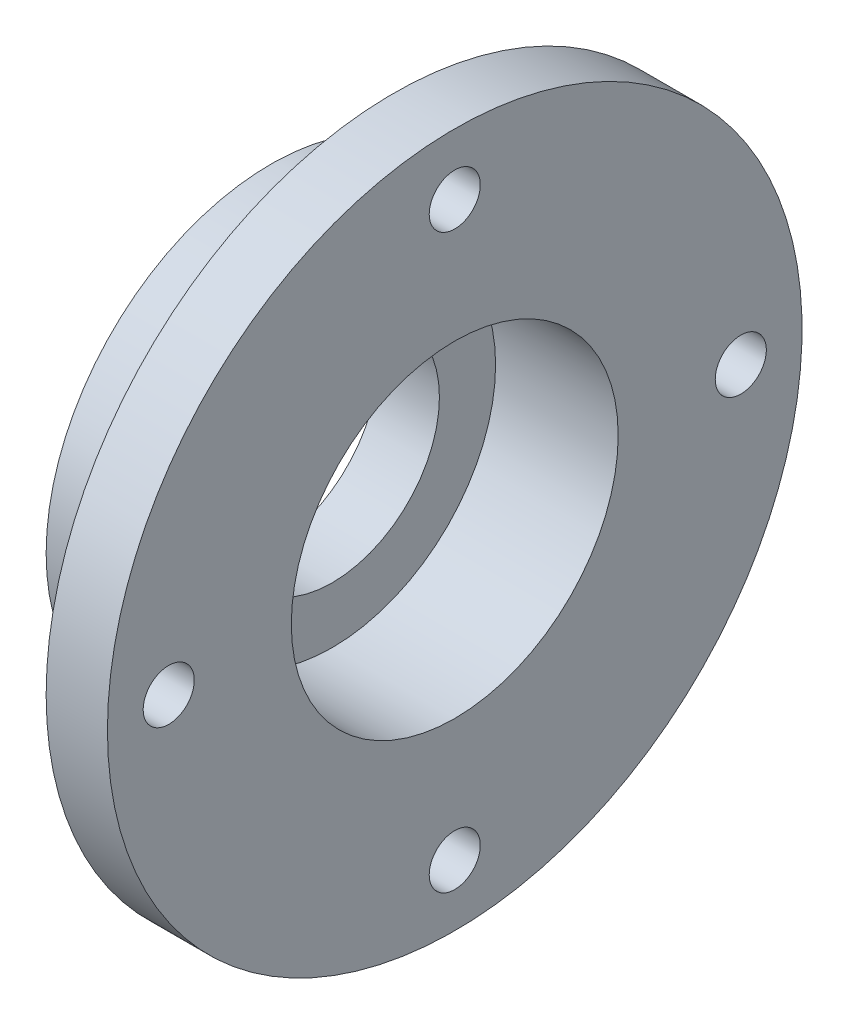
from build123d import *

# Parameters (mm, degrees)
SKETCH2_R          = 2.5
CUT_EXTRUDE1_DEPTH = 7


with BuildPart() as part:
    # Sketch1 → Revolve1 (revolve)
    with BuildSketch(Plane.XY):
        Polygon((0, 16), (0, 34), (-6, 34), (-6, 22), (-18, 22), (-18, 10.5), (-12, 10.5), (-12, 16), align=None)
    revolve(axis=Axis((-41.962696156, 0, 0), (1, 0, 0)))

    # Sketch2 → Cut-Extrude1 (cut, through all)
    with BuildSketch(Plane.ZY.offset(6)):
        with Locations((0, 28)):
            Circle(SKETCH2_R)
        with Locations((28, 0)):
            Circle(SKETCH2_R)
        with Locations((0, -28)):
            Circle(SKETCH2_R)
        with Locations((-28, 0)):
            Circle(SKETCH2_R)
    extrude(amount=-CUT_EXTRUDE1_DEPTH, mode=Mode.SUBTRACT)


solid = part.part
